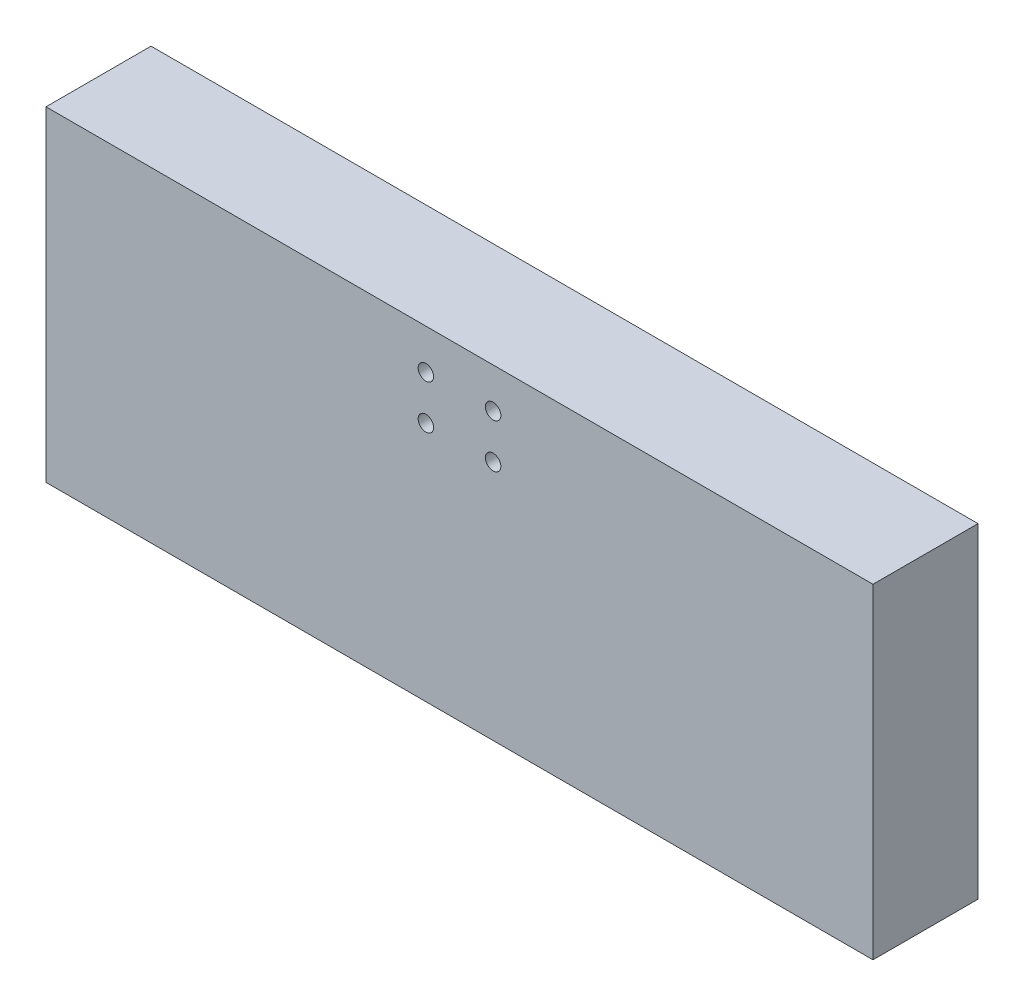
from build123d import *

# Parameters (mm, degrees)
SKETCH1_W           = 150
SKETCH1_H           = 150
BOSS_EXTRUDE1_DEPTH = 59
SKETCH2_W           = 111.9
SKETCH2_H           = 111.9
CUT_EXTRUDE1_DEPTH  = 122.371331047
SKETCH9_R           = 1.4
CUT_EXTRUDE4_DEPTH  = 20
CIRPATTERN1_COUNT   = 3
CIRPATTERN1_ANGLE   = 180
SKETCH10_W          = 111.9
SKETCH10_H          = 105.448295943
CUT_EXTRUDE6_DEPTH  = 122.371331047
SKETCH12_W          = 150
SKETCH12_H          = 130.95
CUT_EXTRUDE7_DEPTH  = 122.371331047


with BuildPart() as part:
    # Sketch1 → Boss-Extrude1 (new body)
    with BuildSketch(Plane(origin=(0, 0, 0), x_dir=(1, 0, 0), z_dir=(0, 1, 0))):
        Rectangle(SKETCH1_W, SKETCH1_H)
    extrude(amount=-BOSS_EXTRUDE1_DEPTH)

    # Sketch2 → Cut-Extrude1 (cut, through all)
    with BuildSketch(Plane(origin=(0, 0, 0), x_dir=(1, 0, 0), z_dir=(0, 1, 0))):
        Rectangle(SKETCH2_W, SKETCH2_H)
    extrude(amount=-CUT_EXTRUDE1_DEPTH, mode=Mode.SUBTRACT)

    # Sketch9 → Cut-Extrude4 (cut)
    with BuildSketch(Plane.ZY.offset(75)):
        with Locations((-6.1, -7.25)):
            Circle(SKETCH9_R)
        with Locations((6.1, -7.25)):
            Circle(SKETCH9_R)
        with Locations((6.1, -15.25)):
            Circle(SKETCH9_R)
        with Locations((-6.1, -15.25)):
            Circle(SKETCH9_R)
    cut_extrude4 = extrude(amount=-CUT_EXTRUDE4_DEPTH, mode=Mode.SUBTRACT)

    # CirPattern1: Cut-Extrude4 ×3 about axis
    cirpattern1_axis = Axis((0, 0, 0), (0, 1, 0))
    for i in range(1, CIRPATTERN1_COUNT):
        add(cut_extrude4.rotate(cirpattern1_axis, i * CIRPATTERN1_ANGLE / (CIRPATTERN1_COUNT - 1)), mode=Mode.SUBTRACT)

    # Sketch10 → Cut-Extrude6 (cut, through all)
    with BuildSketch(Plane(origin=(0, 0, 0), x_dir=(1, 0, 0), z_dir=(0, 1, 0))):
        with Locations((0, 108.674147972)):
            Rectangle(SKETCH10_W, SKETCH10_H)
    extrude(amount=-CUT_EXTRUDE6_DEPTH, mode=Mode.SUBTRACT)

    # Sketch12 → Cut-Extrude7 (cut, through all)
    with BuildSketch(Plane(origin=(0, 0, 0), x_dir=(1, 0, 0), z_dir=(0, 1, 0))):
        with Locations((0, 9.525)):
            Rectangle(SKETCH12_W, SKETCH12_H)
    extrude(amount=-CUT_EXTRUDE7_DEPTH, mode=Mode.SUBTRACT)


solid = part.part
